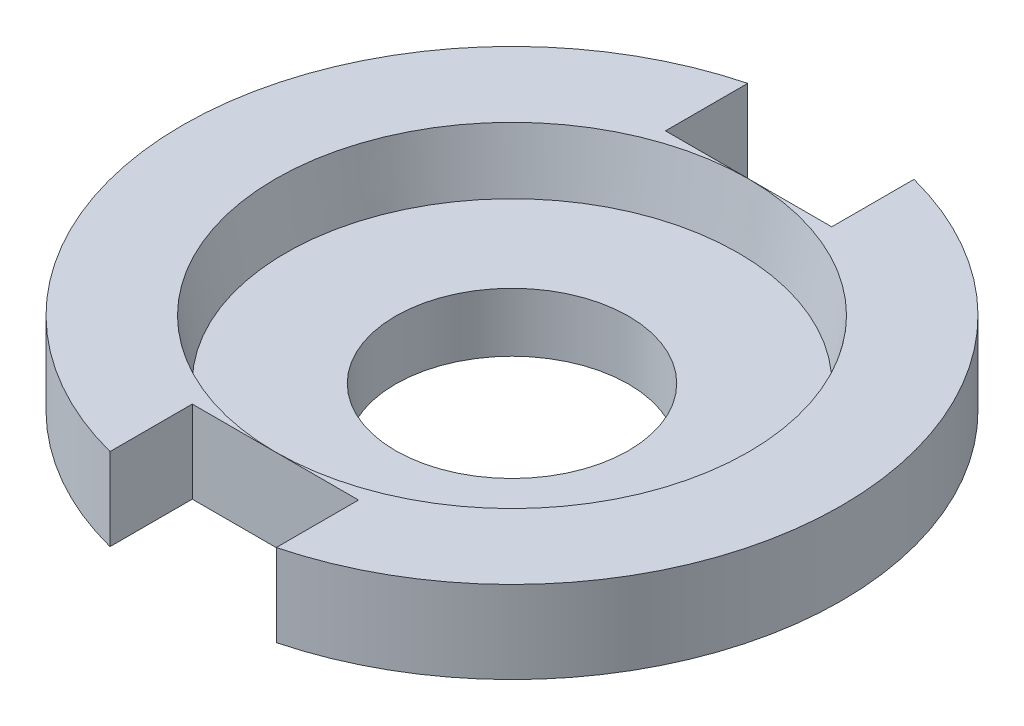
from build123d import *

# Parameters (mm, degrees)
SKETCH1_R           = 28
BOSS_EXTRUDE1_DEPTH = 5
SKETCH2_R           = 20.1
CUT_EXTRUDE1_DEPTH  = 5
CUT_EXTRUDE1_TAPER  = 10
SKETCH3_R           = 28
BOSS_EXTRUDE2_DEPTH = 2
SKETCH4_R           = 14.9
SKETCH4_R_2         = 9.9
BOSS_EXTRUDE3_DEPTH = 3
SKETCH5_R           = 9.9
CUT_EXTRUDE2_DEPTH  = 8.0000001
SKETCH6_W           = 14.1259317
SKETCH6_H           = 9.934859589
SKETCH6_H_2         = 9.890237552
CUT_EXTRUDE3_DEPTH  = 8.0000001


with BuildPart() as part:
    # Sketch1 → Boss-Extrude1 (new body)
    with BuildSketch(Plane(origin=(0, 0, 0), x_dir=(1, 0, 0), z_dir=(0, 1, 0))):
        Circle(SKETCH1_R)
    extrude(amount=BOSS_EXTRUDE1_DEPTH)

    # Sketch2 → Cut-Extrude1 (cut)
    with BuildSketch(Plane(origin=(0, 5, 0), x_dir=(1, 0, 0), z_dir=(0, 1, 0))):
        Circle(SKETCH2_R)
    extrude(amount=-CUT_EXTRUDE1_DEPTH, taper=CUT_EXTRUDE1_TAPER, mode=Mode.SUBTRACT)

    # Sketch3 → Boss-Extrude2 (add)
    with BuildSketch(Plane.XZ):
        Circle(SKETCH3_R)
    extrude(amount=BOSS_EXTRUDE2_DEPTH)

    # Sketch4 → Boss-Extrude3 (add)
    with BuildSketch(Plane(origin=(0, -2, 0), x_dir=(-1, 0, 0), z_dir=(0, -1, 0))):
        Circle(SKETCH4_R)
        Circle(SKETCH4_R_2, mode=Mode.SUBTRACT)
    extrude(amount=BOSS_EXTRUDE3_DEPTH)

    # Sketch5 → Cut-Extrude2 (cut, through all)
    with BuildSketch(Plane(origin=(0, -2, 0), x_dir=(-1, 0, 0), z_dir=(0, -1, 0))):
        Circle(SKETCH5_R)
    extrude(amount=-CUT_EXTRUDE2_DEPTH, mode=Mode.SUBTRACT)

    # Sketch6 → Cut-Extrude3 (cut, through all)
    with BuildSketch(Plane.XZ.offset(2)):
        with Locations((0, -25.072591843)):
            Rectangle(SKETCH6_W, SKETCH6_H)
        with Locations((0, 25.050280825)):
            Rectangle(SKETCH6_W, SKETCH6_H_2)
    extrude(amount=-CUT_EXTRUDE3_DEPTH, mode=Mode.SUBTRACT)


solid = part.part
